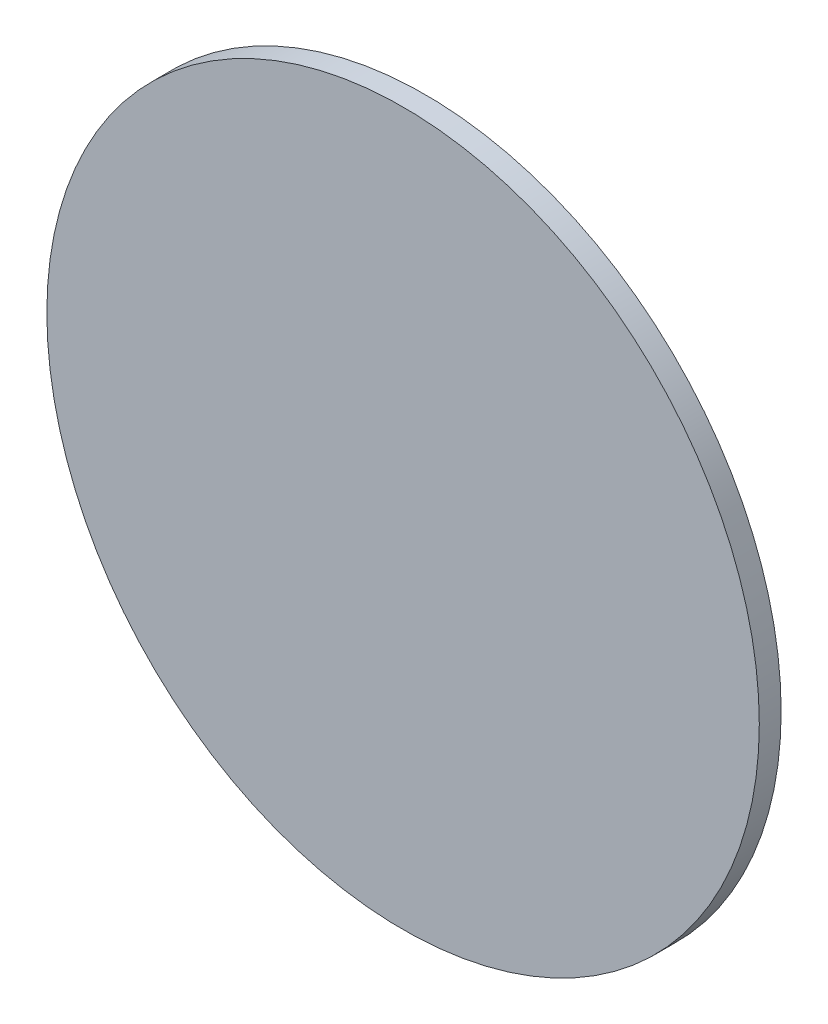
from build123d import *

# Parameters (mm, degrees)
SKETCH_1_R      = 37.5
EXTRUDE_1_DEPTH = 2.3


with BuildPart() as part:
    # 草图1 → 凸台-拉伸1 (new body)
    with BuildSketch(Plane.XY):
        with Locations((-5.457823936, 0)):
            Circle(SKETCH_1_R)
    extrude(amount=EXTRUDE_1_DEPTH)


solid = part.part
